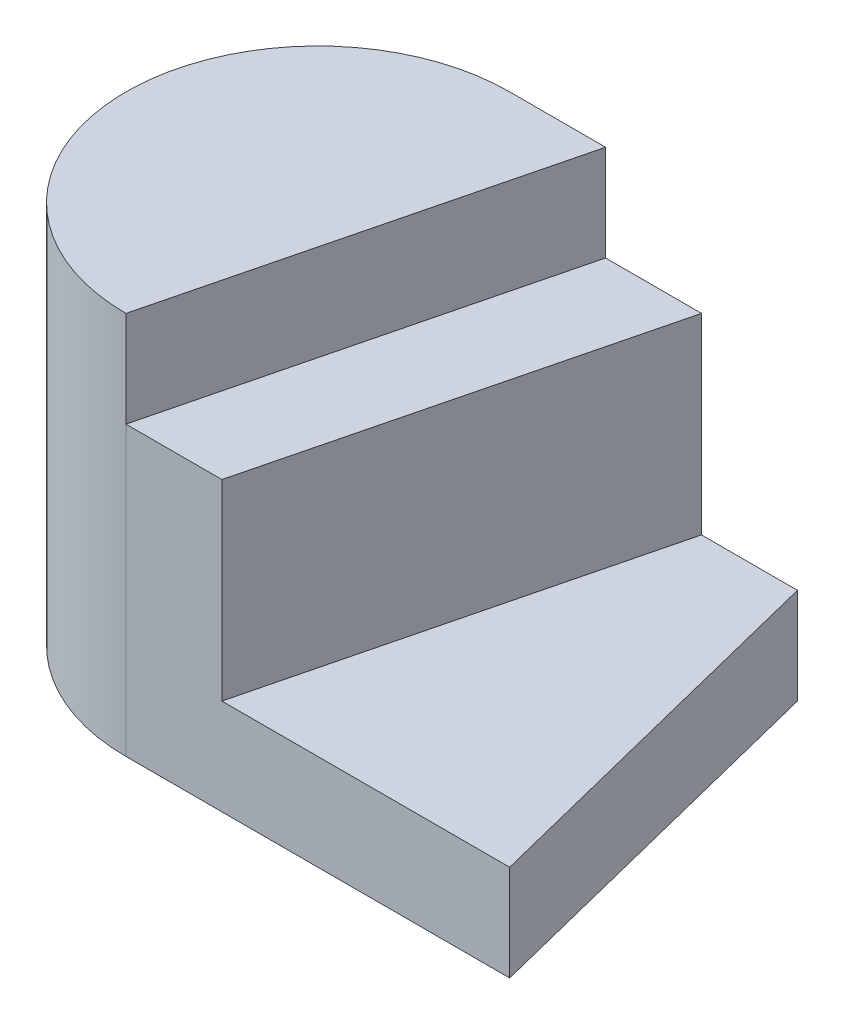
from build123d import *

# Parameters (mm, degrees)
BOSS_EXTRUDE1_DEPTH = 254
BOSS_EXTRUDE2_DEPTH = 762
BOSS_EXTRUDE3_DEPTH = 1016


with BuildPart() as part:
    # Sketch1 → Boss-Extrude1 (new body)
    with BuildSketch(Plane(origin=(0, 0, 0), x_dir=(1, 0, 0), z_dir=(0, 1, 0))):
        Polygon((762, 508), (508, 508), (254, -508), (1016, -508), align=None)
    extrude(amount=BOSS_EXTRUDE1_DEPTH)

    # Sketch1_3 → Boss-Extrude2 (add)
    with BuildSketch(Plane(origin=(0, 0, 0), x_dir=(1, 0, 0), z_dir=(0, 1, 0))):
        Polygon((508, 508), (254, 508), (0, -508), (254, -508), align=None)
    extrude(amount=BOSS_EXTRUDE2_DEPTH)

    # Sketch1_4 → Boss-Extrude3 (add)
    with BuildSketch(Plane(origin=(0, 0, 0), x_dir=(1, 0, 0), z_dir=(0, 1, 0))):
        with BuildLine():
            Line((254, 508), (0, 508))
            ThreePointArc((0, 508), (-508, 0), (0, -508))
            Line((0, -508), (254, 508))
        make_face()
    extrude(amount=BOSS_EXTRUDE3_DEPTH)


solid = part.part
